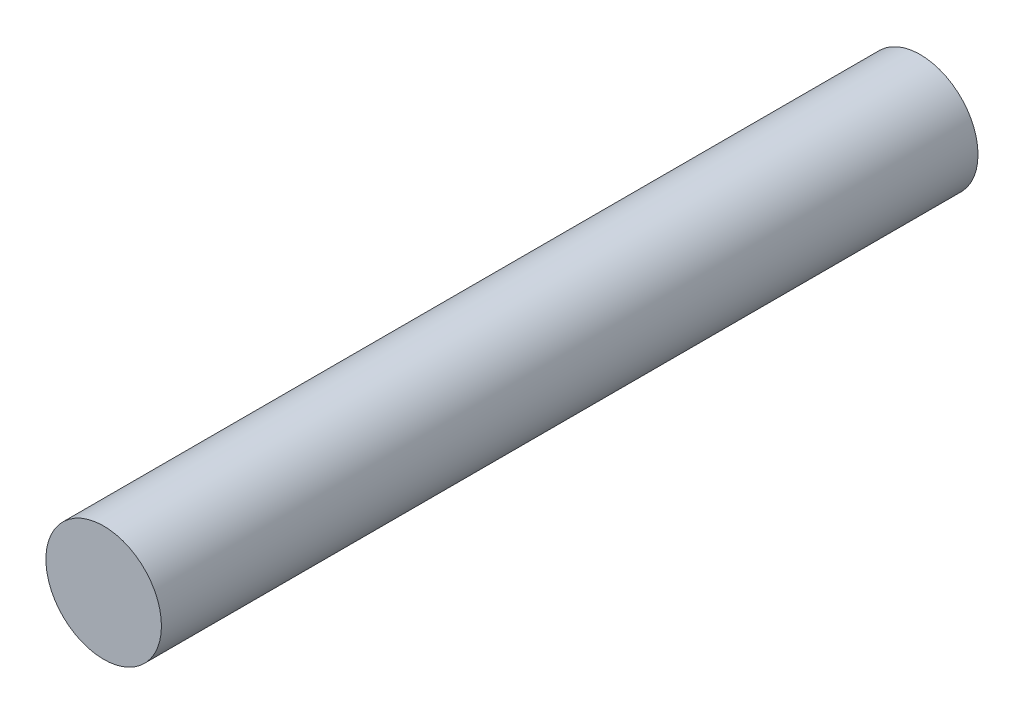
from build123d import *

# Parameters (mm, degrees)
CROQUIS1_R              = 7.5
SALIENTE_EXTRUIR1_DEPTH = 53


with BuildPart() as part:
    # Croquis1 → Saliente-Extruir1 (new body, symmetric)
    with BuildSketch(Plane.XY):
        Circle(CROQUIS1_R)
    extrude(amount=SALIENTE_EXTRUIR1_DEPTH, both=True)


solid = part.part
